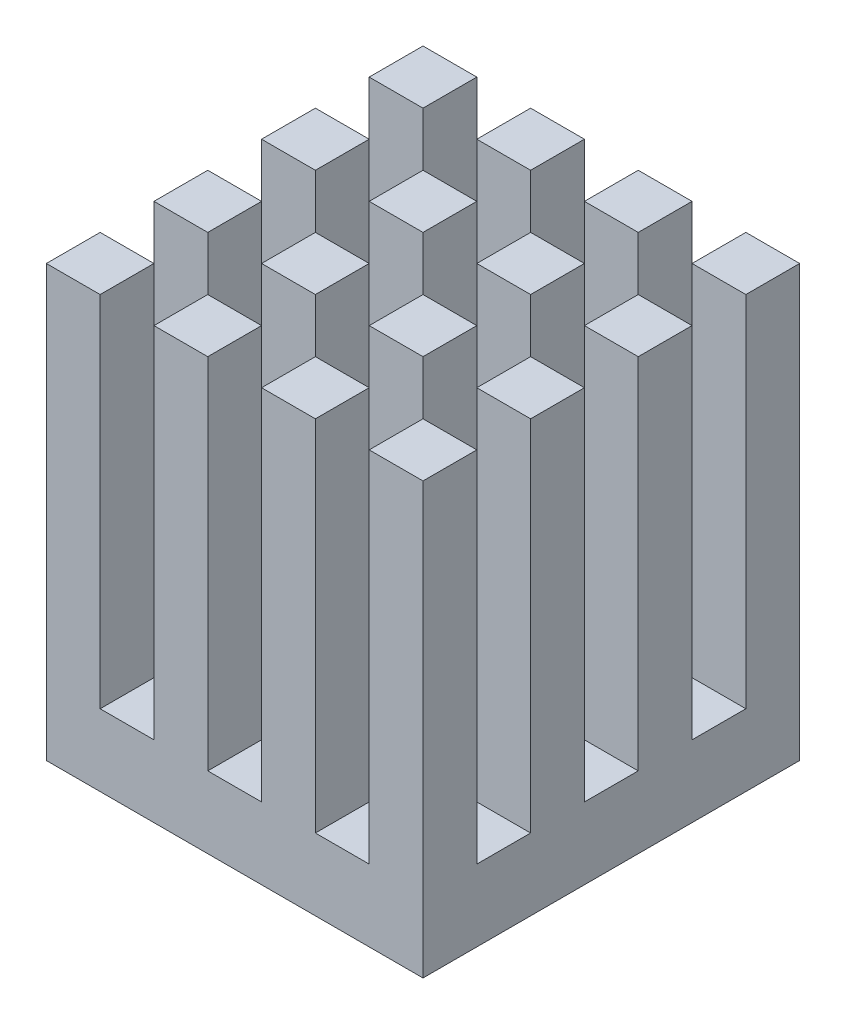
from build123d import *

# Parameters (mm, degrees)
SKETCH1_W            = 10.5
SKETCH1_H            = 10.5
BOSS_EXTRUDE1_DEPTH  = 2
SKETCH2_W            = 1.5
SKETCH2_H            = 1.5
BOSS_EXTRUDE2_DEPTH  = 10
LPATTERN1_COUNT      = 4
LPATTERN1_PITCH      = 3
LPATTERN1_COUNT_DIR2 = 4
LPATTERN1_PITCH_DIR2 = 3


with BuildPart() as part:
    # Sketch1 → Boss-Extrude1 (new body)
    with BuildSketch(Plane(origin=(0, 0, 0), x_dir=(1, 0, 0), z_dir=(0, 1, 0))):
        Rectangle(SKETCH1_W, SKETCH1_H)
    extrude(amount=BOSS_EXTRUDE1_DEPTH)

    # Sketch2 → Boss-Extrude2 (add)
    with BuildSketch(Plane(origin=(0, 2, 0), x_dir=(1, 0, 0), z_dir=(0, 1, 0))):
        with Locations((-4.5, 4.5)):
            Rectangle(SKETCH2_W, SKETCH2_H)
    boss_extrude2 = extrude(amount=BOSS_EXTRUDE2_DEPTH)

    # LPattern1: Boss-Extrude2 4 × 4
    with Locations(*[(i * LPATTERN1_PITCH, 0, j * LPATTERN1_PITCH_DIR2) for i in range(LPATTERN1_COUNT) for j in range(LPATTERN1_COUNT_DIR2) if (i, j) != (0, 0)]):
        add(boss_extrude2)


solid = part.part
